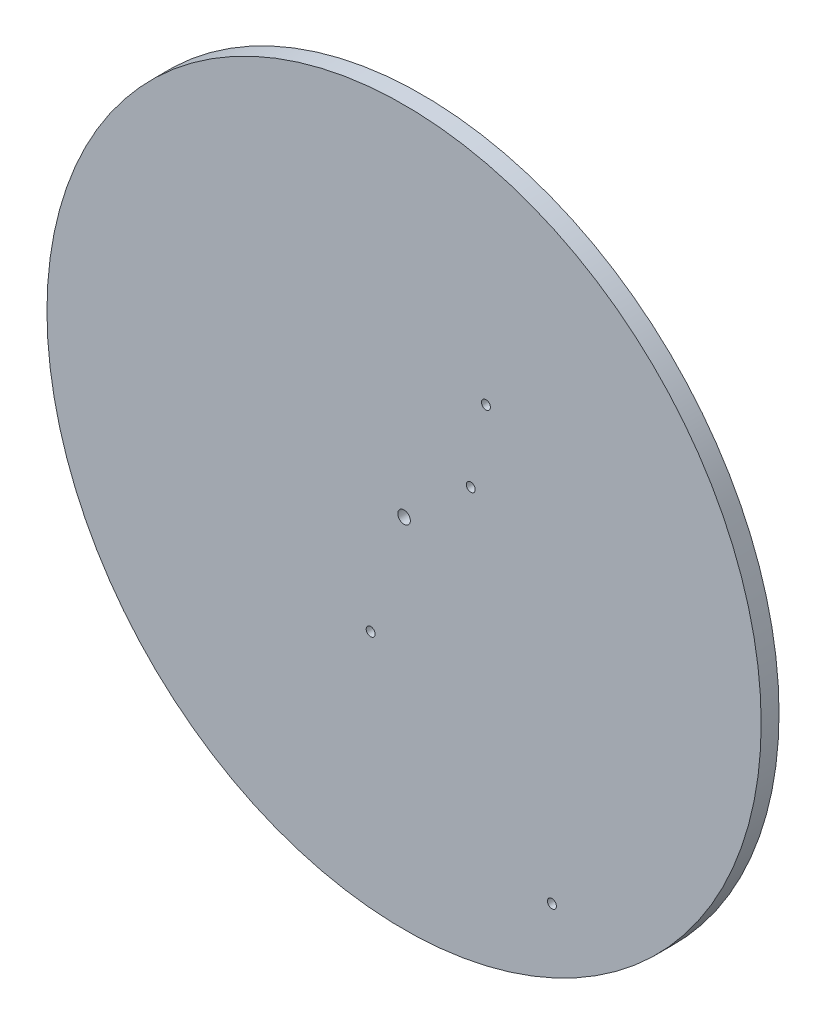
from build123d import *

# Parameters (mm, degrees)
SKETCH1_R           = 200
SKETCH1_R_2         = 3.5
BOSS_EXTRUDE1_DEPTH = 10
SKETCH2_R           = 2.5
CUT_EXTRUDE1_DEPTH  = 11
SKETCH3_R           = 2.5
CUT_EXTRUDE2_DEPTH  = 11
SKETCH4_R           = 2.5
CUT_EXTRUDE3_DEPTH  = 11


with BuildPart() as part:
    # Sketch1 → Boss-Extrude1 (new body)
    with BuildSketch(Plane.XY):
        Circle(SKETCH1_R)
        Circle(SKETCH1_R_2, mode=Mode.SUBTRACT)
    extrude(amount=BOSS_EXTRUDE1_DEPTH)

    # Sketch2 → Cut-Extrude1 (cut, through all)
    with BuildSketch(Plane.XY.offset(10)):
        with Locations((37.34, 33.25)):
            Circle(SKETCH2_R)
        with Locations((45.86, 77.44)):
            Circle(SKETCH2_R)
    extrude(amount=-CUT_EXTRUDE1_DEPTH, mode=Mode.SUBTRACT)

    # Sketch3 → Cut-Extrude2 (cut, through all)
    with BuildSketch(Plane.XY.offset(10)):
        with Locations((-18.71, -64.86)):
            Circle(SKETCH3_R)
    extrude(amount=-CUT_EXTRUDE2_DEPTH, mode=Mode.SUBTRACT)

    # Sketch4 → Cut-Extrude3 (cut, through all)
    with BuildSketch(Plane.XY.offset(10)):
        with Locations((82.82, -146.05)):
            Circle(SKETCH4_R)
    extrude(amount=-CUT_EXTRUDE3_DEPTH, mode=Mode.SUBTRACT)


solid = part.part
